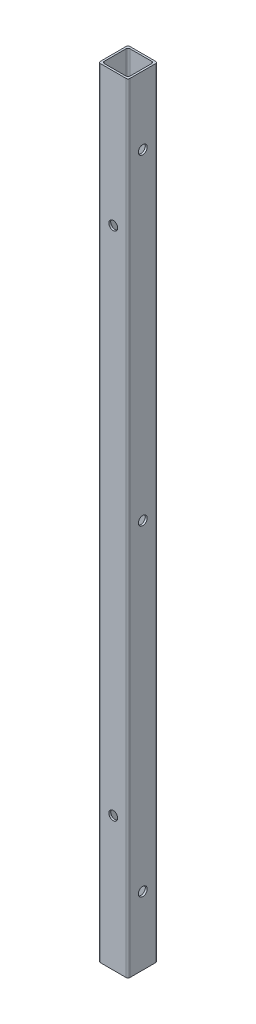
from build123d import *

# Parameters (mm, degrees)
SKETCH1_W                  = 19.304
SKETCH1_H                  = 19.304
SKETCH1_W_2                = 16.764
SKETCH1_H_2                = 16.764
BOSS_EXTRUDE1_DEPTH        = 508
FILLET1_R                  = 1.27
F_1_0_228_DIAMETER_HOLE2_D = 5.7912
F_1_0_228_DIAMETER_HOLE3_D = 5.7912


with BuildPart() as part:
    # Sketch1 → Boss-Extrude1 (new body)
    with BuildSketch(Plane(origin=(0, 0, 0), x_dir=(1, 0, 0), z_dir=(0, 1, 0))):
        Rectangle(SKETCH1_W, SKETCH1_H)
        Rectangle(SKETCH1_W_2, SKETCH1_H_2, mode=Mode.SUBTRACT)
    extrude(amount=BOSS_EXTRUDE1_DEPTH)

    # Fillet1
    fillet1_edges = [part.edges().sort_by_distance(p)[0] for p in [
        (-8.382, 254, 8.382),
        (8.382, 254, 8.382),
        (8.382, 254, -8.382),
        (-8.382, 254, -8.382),
        (9.652, 254, 9.652),
        (-9.652, 254, 9.652),
        (-9.652, 254, -9.652),
        (9.652, 254, -9.652),
    ]]
    fillet(fillet1_edges, radius=FILLET1_R)

    # #1 (0.228) Diameter Hole2 (through all)
    with Locations(Plane.ZY.offset(9.652)):
        with Locations((0, 463.55), (0, 44.45), (0, 254)):
            Hole(F_1_0_228_DIAMETER_HOLE2_D / 2)

    # #1 (0.228) Diameter Hole3 (through all)
    with Locations(Plane(origin=(0, 0, -9.652), x_dir=(-1, 0, 0), z_dir=(0, 0, -1))):
        with Locations((0, 420.6875), (0, 87.3125)):
            Hole(F_1_0_228_DIAMETER_HOLE3_D / 2)


solid = part.part
